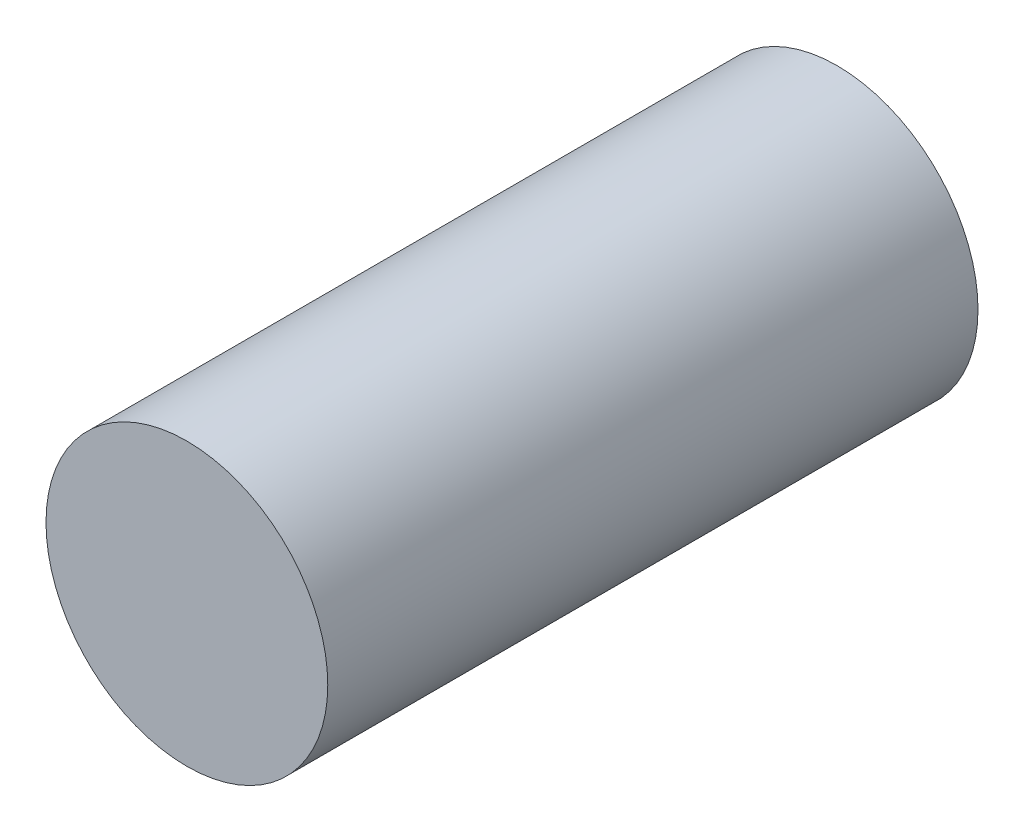
from build123d import *

# Parameters (mm, degrees)
SKETCH1_R           = 6.5
BOSS_EXTRUDE1_DEPTH = 30


with BuildPart() as part:
    # Sketch1 → Boss-Extrude1 (new body)
    with BuildSketch(Plane.XY):
        Circle(SKETCH1_R)
    extrude(amount=BOSS_EXTRUDE1_DEPTH)


solid = part.part
